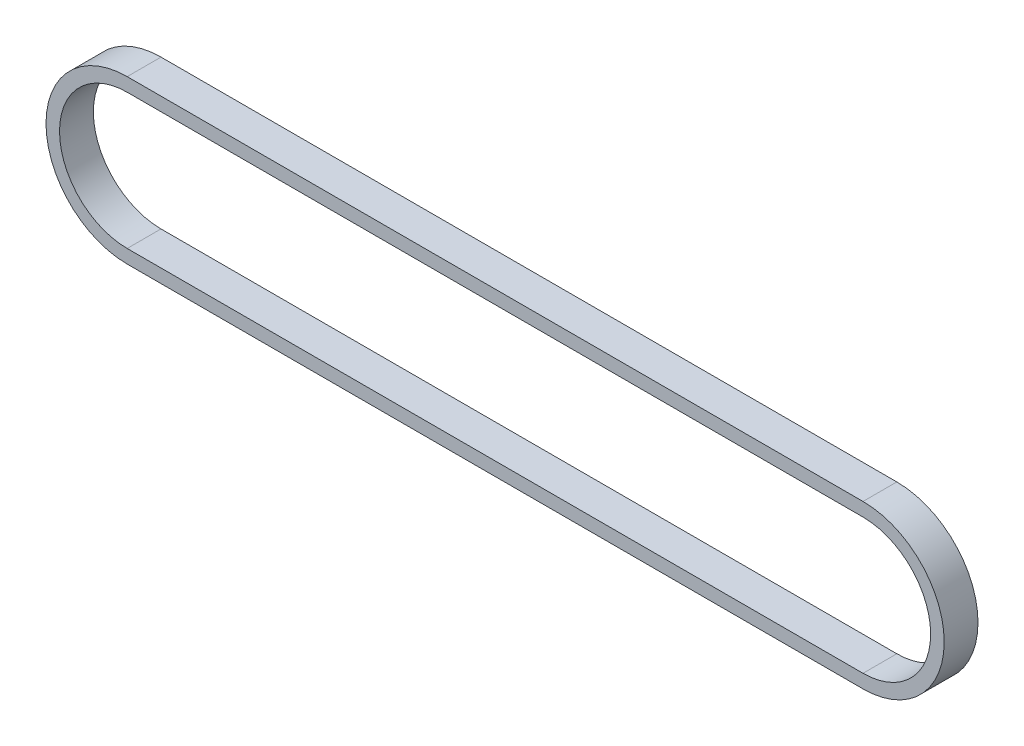
from build123d import *

# Parameters (mm, degrees)
BOSS_EXTRUDE1_DEPTH = 6.35


with BuildPart() as part:
    # Sketch1 → Boss-Extrude1 (new body)
    with BuildSketch(Plane.XY):
        with BuildLine():
            Line((0, 15.24), (138.151108, 15.24))
            ThreePointArc((138.151108, 15.24), (153.391108, 0), (138.151108, -15.24))
            Line((138.151108, -15.24), (0, -15.24))
            ThreePointArc((0, -15.24), (-15.24, 0), (0, 15.24))
        make_face()
        with BuildLine():
            Line((0, 12.7), (138.151108, 12.7))
            ThreePointArc((138.151108, 12.7), (150.851108, 0), (138.151108, -12.7))
            Line((138.151108, -12.7), (0, -12.7))
            ThreePointArc((0, -12.7), (-12.7, 0), (0, 12.7))
        make_face(mode=Mode.SUBTRACT)
    extrude(amount=BOSS_EXTRUDE1_DEPTH)


solid = part.part
